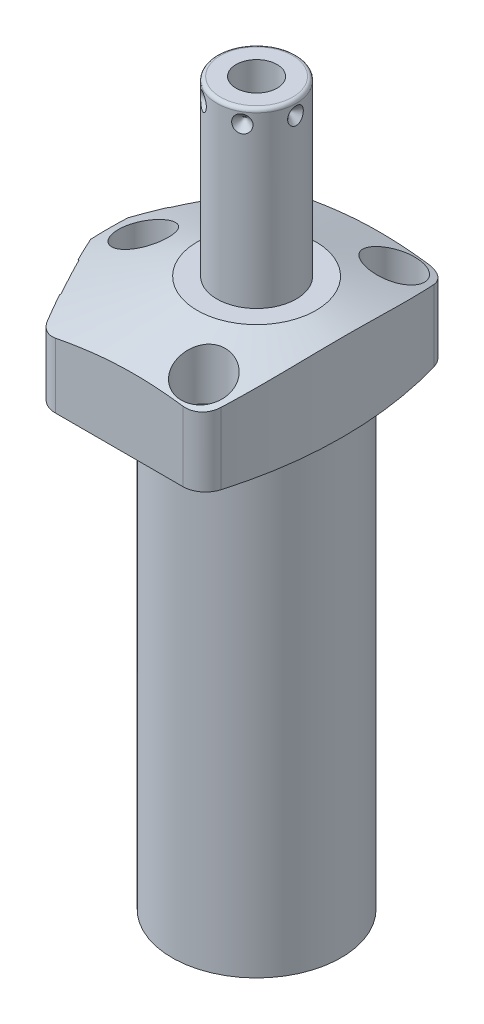
from build123d import *

# Parameters (mm, degrees)
CUT_EXTRUDE1_REACH = 28.975
CUT_EXTRUDE2_REACH = 28.975
S2D0002_OUTSIDE_W  = 128.517
S2D0002_OUTSIDE_H  = 108.858
CUT_EXTRUDE3_DEPTH = 26.9748
FILLET1_R          = 6.35
FILLET2_R          = 6.35
FILLET3_R          = 6.35
SKETCH17_R         = 10.4775
CUT_EXTRUDE4_DEPTH = 0.254
SKETCH18_R         = 5.5626
CUT_EXTRUDE5_DEPTH = 2.667
CIRPATTERN1_COUNT  = 6
HOLE1_D            = 8.7376
HOLE1_DEPTH        = 26.9748
HOLE1_CBORE_D      = 13.9954
HOLE1_CBORE_DEPTH  = 16.6624


with BuildPart() as part:
    # Sketch1 → Revolve1 (revolve)
    with BuildSketch(Plane.XY, mode=Mode.PRIVATE) as revolve1_sk:
        Polygon((44.45, 0), (44.45, 26.9748), (0, 26.9748), (0, -126.5682), (23.6855, -126.5682), (23.6855, 0), align=None)
    revolve(revolve1_sk.sketch.rotate(Axis((0, 32.53105, 0), (0, -1, 0)), 180), axis=Axis((0, 32.53105, 0), (0, -1, 0)))  # turned: the seam where the file's is

    # Sketch2 → Cut-Extrude1 (cut, up to next)
    with BuildSketch(Plane.XZ, mode=Mode.PRIVATE) as cut_extrude1_sk1:
        with BuildLine():
            Line((-28.129568269, -34.417), (28.129568269, -34.417))
            ThreePointArc((28.129568269, -34.417), (0, -44.45), (-28.129568269, -34.417))
        make_face()
    cut_extrude1_tool1 = extrude(cut_extrude1_sk1.sketch, amount=-CUT_EXTRUDE1_REACH, mode=Mode.PRIVATE) & part.part
    add(cut_extrude1_tool1.solids().sort_by_distance((0, 0, -38.471745))[0], mode=Mode.SUBTRACT)
    # Sketch2 → Cut-Extrude1 (cut, up to next)
    with BuildSketch(Plane.XZ, mode=Mode.PRIVATE) as cut_extrude1_sk2:
        with BuildLine():
            Line((28.129568269, 34.417), (-28.129568269, 34.417))
            ThreePointArc((-28.129568269, 34.417), (0, 44.45), (28.129568269, 34.417))
        make_face()
    cut_extrude1_tool2 = extrude(cut_extrude1_sk2.sketch, amount=-CUT_EXTRUDE1_REACH, mode=Mode.PRIVATE) & part.part
    add(cut_extrude1_tool2.solids().sort_by_distance((0, 0, 38.471745))[0], mode=Mode.SUBTRACT)

    # Sketch3 → Cut-Extrude2 (cut, up to next)
    with BuildSketch(Plane.XZ, mode=Mode.PRIVATE) as cut_extrude2_sk1:
        with BuildLine():
            Line((-25.74286108, -34.417), (-44.042704589, 0))
            Line((-44.042704589, 0), (-25.74286108, 34.417))
            Line((-25.74286108, 34.417), (-28.129568269, 34.417))
            ThreePointArc((-28.129568269, 34.417), (-44.45, 0), (-28.129568269, -34.417))
            Line((-28.129568269, -34.417), (-25.74286108, -34.417))
        make_face()
    cut_extrude2_tool1 = extrude(cut_extrude2_sk1.sketch, amount=-CUT_EXTRUDE2_REACH, mode=Mode.PRIVATE) & part.part
    add(cut_extrude2_tool1.solids().sort_by_distance((-35.522596, 0, -17.543378))[0], mode=Mode.SUBTRACT)

    # S2D0002 outside → Cut-Extrude3 (cut)
    with BuildSketch(Plane(origin=(0, 26.9748, 0), x_dir=(-1, 0, 0), z_dir=(0, -1, 0))):
        with Locations((-0.2035, 0)):
            Rectangle(S2D0002_OUTSIDE_W, S2D0002_OUTSIDE_H)
        with BuildLine():
            Line((41.275, 98.168864142), (41.275, -98.168864142))
            ThreePointArc((41.275, -98.168864142), (-24.13, 0), (41.275, 98.168864142))
        make_face(mode=Mode.SUBTRACT)
    extrude(amount=CUT_EXTRUDE3_DEPTH, mode=Mode.SUBTRACT)

    # Fillet1
    fillet1_edges = [part.edges().sort_by_distance(p)[0] for p in [
        (18.408430268, 13.4874, 34.417),
        (18.408430268, 13.4874, -34.417),
    ]]
    fillet(fillet1_edges, radius=FILLET1_R)

    # Fillet2
    fillet2_edges = [part.edges().sort_by_distance(p)[0] for p in [
        (-25.74286108, 13.4874, 34.417),
    ]]
    fillet(fillet2_edges, radius=FILLET2_R)

    # Fillet3
    fillet3_edges = [part.edges().sort_by_distance(p)[0] for p in [
        (-25.74286108, 13.4874, -34.417),
    ]]
    fillet(fillet3_edges, radius=FILLET3_R)

    # Sketch5 → Cut-Revolve1 (revolve, cut)
    with BuildSketch(Plane.XY):
        Polygon((-16.637, 26.9748), (-47.625, 15.696090381), (-47.625, 26.9748), align=None)
    revolve(axis=Axis((0, 7.66490951, 0), (0, 1, 0)), mode=Mode.SUBTRACT)

    # Sketch6 → Cut-Revolve2 (revolve, cut)
    with BuildSketch(Plane(origin=(-34.111267534, 10.287, -18.137282674), x_dir=(0.469471563, 0, -0.882947593), z_dir=(0, 1, 0))):
        Polygon((0, 0), (6.1849, 0), (5.642306865, -2.5527), (4.9784, -3.216606865), (4.9784, -15.748), (0, -15.748), align=None)
    revolve(axis=Axis((-19.511375907, 10.287, -10.374382594), (-0.882947593, 0, -0.469471563)), mode=Mode.SUBTRACT)

    # Sketch7 → Cut-Revolve3 (revolve, cut)
    with BuildSketch(Plane(origin=(-34.111267534, 10.287, 18.137282674), x_dir=(-0.469471563, 0, -0.882947593), z_dir=(0, 1, 0))):
        Polygon((0, 0), (6.1849, 0), (5.642306865, -2.5527), (4.9784, -3.216606865), (4.9784, -15.748), (0, -15.748), align=None)
    revolve(axis=Axis((-19.511375907, 10.287, 10.374382594), (-0.882947593, 0, 0.469471563)), mode=Mode.SUBTRACT)

    # Sketch9 → Cut-Revolve5 (revolve, cut)
    with BuildSketch(Plane(origin=(-13.4874, 2.667, 26.5938), x_dir=(-1, 0, 0), z_dir=(0, 0, 1)), mode=Mode.PRIVATE) as cut_revolve5_sk:
        Polygon((5.5626, 0), (10.1092, 0), (9.669186662, -2.0701), (9.017, -2.722286662), (9.017, -12.573), (5.5626, -12.573), align=None)
    cut_revolve5 = revolve(cut_revolve5_sk.sketch.rotate(Axis((-19.05, 15.86865, 26.5938), (0, -1, 0)), 270), axis=Axis((-19.05, 15.86865, 26.5938), (0, -1, 0)), mode=Mode.SUBTRACT)  # turned: the seam where the file's is

    # Sketch17 → Cut-Extrude4 (cut)
    with BuildSketch(Plane(origin=(-34.335536223, 0, 18.256528451), x_dir=(0.469471563, 0, 0.882947593), z_dir=(-0.882947593, 0, 0.469471563))):
        with Locations((0, 10.287)):
            Circle(SKETCH17_R)
    cut_extrude4 = extrude(amount=-CUT_EXTRUDE4_DEPTH, mode=Mode.SUBTRACT)

    # Sketch18 → Cut-Extrude5 (cut)
    with BuildSketch(Plane.XZ):
        with Locations(Location((-19.05, 26.5938, 0), (0, 0, 270))):  # turned: the seam where the file's is
            Circle(SKETCH18_R)
    cut_extrude5 = extrude(amount=-CUT_EXTRUDE5_DEPTH, mode=Mode.SUBTRACT)

    # Mirror1: Cut-Revolve5, Cut-Extrude4, Cut-Extrude5 across plane
    add(cut_revolve5.mirror(Plane.XY), mode=Mode.SUBTRACT)
    add(cut_extrude4.mirror(Plane.XY), mode=Mode.SUBTRACT)
    add(cut_extrude5.mirror(Plane.XY), mode=Mode.SUBTRACT)

    # Sketch10 → Revolve2 (revolve)
    with BuildSketch(Plane(origin=(0, 0, 0), x_dir=(0, 0, -1), z_dir=(1, 0, 0)), mode=Mode.PRIVATE) as revolve2_sk:
        with BuildLine():
            Line((0, 26.9748), (-11.1125, 26.9748))
            Line((-11.1125, 26.9748), (-11.1125, 74.4474))
            ThreePointArc((-11.1125, 74.4474), (-10.81492049, 75.16582049), (-10.0965, 75.4634))
            Line((-10.0965, 75.4634), (0, 75.4634))
            Line((0, 75.4634), (0, 26.9748))
        make_face()
    revolve(revolve2_sk.sketch.rotate(Axis((0, 14.351681477, 0), (0, 1, 0)), 180), axis=Axis((0, 14.351681477, 0), (0, 1, 0)))  # turned: the seam where the file's is

    # S2D0001 → Cut-Revolve6 (revolve, cut)
    with BuildSketch(Plane.XY, mode=Mode.PRIVATE) as cut_revolve6_sk:
        Polygon((5.7531, 75.4634), (5.7531, 58.4454), (0, 54.988588773), (0, 75.4634), align=None)
    revolve(cut_revolve6_sk.sketch.rotate(Axis((0, -27.736317225, 0), (0, 1, 0)), 90), axis=Axis((0, -27.736317225, 0), (0, 1, 0)), mode=Mode.SUBTRACT)  # turned: the seam where the file's is

    # Sketch14 → Revolve3 (revolve)
    with BuildSketch(Plane(origin=(-13.4874, 0, 26.5938), x_dir=(-1, 0, 0), z_dir=(0, 0, -1)), mode=Mode.PRIVATE) as revolve3_sk:
        with BuildLine():
            Line((11.0236, 2.667), (11.0236, 0.9398))
            Line((11.0236, 0.9398), (10.864159456, 0.9398))
            ThreePointArc((10.864159456, 0.9398), (10.1346, -0.4572), (9.405040544, 0.9398))
            Line((9.405040544, 0.9398), (8.7376, 0.9398))
            ThreePointArc((8.7376, 0.9398), (8.378389755, 0.791010245), (8.2296, 0.4318))
            Line((8.2296, 0.4318), (8.2296, 0.127))
            Line((8.2296, 0.127), (7.1501, 0.127))
            Line((7.1501, 0.127), (7.1501, 10.6172))
            Line((7.1501, 10.6172), (8.8138, 10.6172))
            Line((8.8138, 10.6172), (8.8138, 2.667))
            Line((8.8138, 2.667), (11.0236, 2.667))
        make_face()
    revolve3 = revolve(revolve3_sk.sketch.rotate(Axis((-19.05, -1.01092, 26.5938), (0, 1, 0)), 270), axis=Axis((-19.05, -1.01092, 26.5938), (0, 1, 0)))  # turned: the seam where the file's is

    # Sketch15 → Cut-Revolve7 (revolve, cut)
    with BuildSketch(Plane(origin=(-11.1125, 60.8838, 0), x_dir=(0, 1, 0), z_dir=(0, 0, 1)), mode=Mode.PRIVATE) as cut_revolve7_sk:
        Polygon((10.6172, 0), (13.0302, 0), (10.6172, -2.413), align=None)
    cut_revolve7 = revolve(cut_revolve7_sk.sketch.rotate(Axis((-6.003069898, 71.501, 0), (-1, 0, 0)), 270), axis=Axis((-6.003069898, 71.501, 0), (-1, 0, 0)), mode=Mode.SUBTRACT)  # turned: the seam where the file's is

    # CirPattern1: Cut-Revolve7 ×6 about axis
    cirpattern1_axis = Axis((0, 14.351681477, 0), (0, -1, 0))
    for i in range(1, CIRPATTERN1_COUNT):
        add(cut_revolve7.rotate(cirpattern1_axis, i * 360 / CIRPATTERN1_COUNT), mode=Mode.SUBTRACT)

    # Hole1
    with Locations(Plane(origin=(0, 26.9748, 0), x_dir=(-1, 0, 0), z_dir=(0, 1, 0))):
        with Locations((-11.8872, -26.67), (31.75, 0), (-11.8872, 26.67)):
            CounterBoreHole(HOLE1_D / 2, HOLE1_CBORE_D / 2, HOLE1_CBORE_DEPTH, depth=HOLE1_DEPTH)

    # Mirror2: Revolve3 across plane
    add(revolve3.mirror(Plane.XY))


solid = part.part
